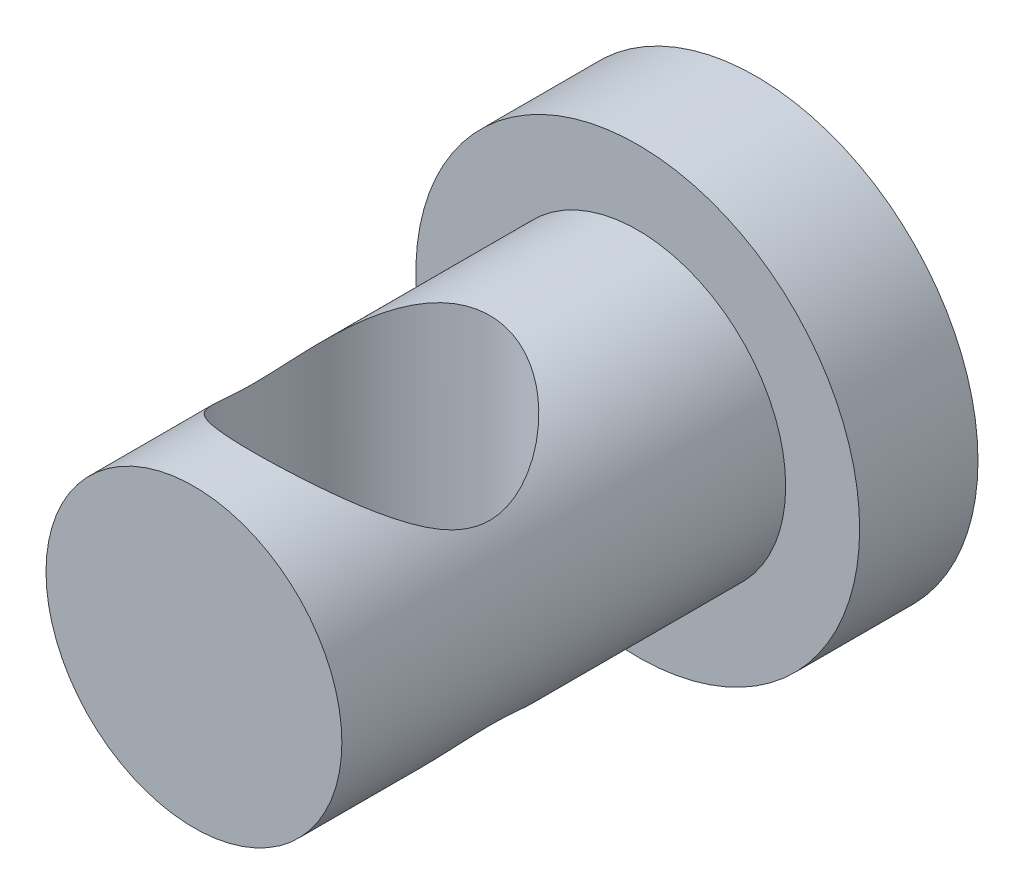
from build123d import *

# Parameters (mm, degrees)
SKETCH1_R           = 7.5
BOSS_EXTRUDE1_DEPTH = 4
SKETCH2_R           = 5
BOSS_EXTRUDE2_DEPTH = 15
SKETCH3_R           = 4
CUT_EXTRUDE1_DEPTH  = 7


with BuildPart() as part:
    # Sketch1 → Boss-Extrude1 (new body)
    with BuildSketch(Plane.XY):
        Circle(SKETCH1_R)
    extrude(amount=BOSS_EXTRUDE1_DEPTH)

    # Sketch2 → Boss-Extrude2 (add)
    with BuildSketch(Plane.XY.offset(4)):
        Circle(SKETCH2_R)
    extrude(amount=BOSS_EXTRUDE2_DEPTH)

    # Sketch3 → Cut-Extrude1 (cut, symmetric)
    with BuildSketch(Plane(origin=(0, 0, 0), x_dir=(1, 0, 0), z_dir=(0, 1, 0))):
        with Locations((0, -13)):
            Circle(SKETCH3_R)
    extrude(amount=CUT_EXTRUDE1_DEPTH, both=True, mode=Mode.SUBTRACT)


solid = part.part
